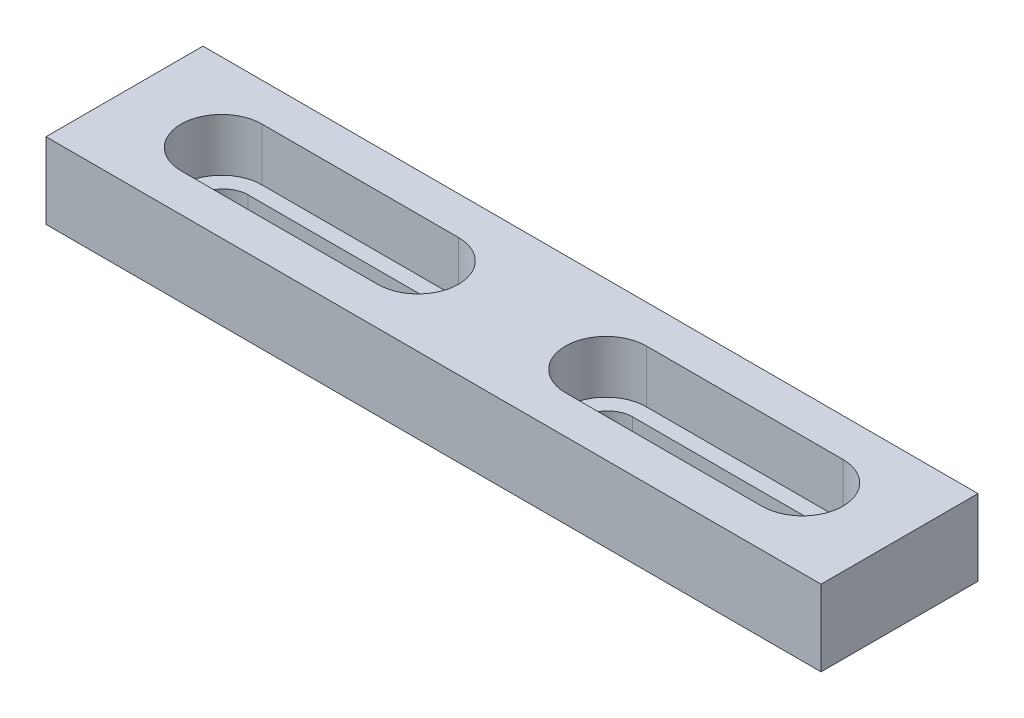
from build123d import *

# Parameters (mm, degrees)
SKETCH_2_W          = 100
SKETCH_2_H          = 20.25
EXTRUDE_2_DEPTH     = 9.8
CUT_EXTRUDE_4_DEPTH = 9.8
EXTRUDE_3_DEPTH     = 3


with BuildPart() as part:
    # 草图2 → 凸台-拉伸2 (new body)
    with BuildSketch(Plane(origin=(0, 0, 0), x_dir=(1, 0, 0), z_dir=(0, 1, 0))):
        Rectangle(SKETCH_2_W, SKETCH_2_H)
    extrude(amount=EXTRUDE_2_DEPTH)

    # 草图6 → 切除-拉伸4 (cut)
    with BuildSketch(Plane(origin=(0, 0, 0), x_dir=(1, 0, 0), z_dir=(0, 1, 0))):
        with BuildLine():
            Line((-37.475, 5.225), (-12.125, 5.225))
            ThreePointArc((-12.125, 5.225), (-6.9, 0), (-12.125, -5.225))
            Line((-12.125, -5.225), (-37.475, -5.225))
            ThreePointArc((-37.475, -5.225), (-42.7, 0), (-37.475, 5.225))
        make_face()
        with BuildLine():
            Line((37.475, -5.225), (12.125, -5.225))
            ThreePointArc((12.125, -5.225), (6.9, 0), (12.125, 5.225))
            Line((12.125, 5.225), (37.475, 5.225))
            ThreePointArc((37.475, 5.225), (42.7, 0), (37.475, -5.225))
        make_face()
    extrude(amount=CUT_EXTRUDE_4_DEPTH, mode=Mode.SUBTRACT)

    # 草图8 → 凸台-拉伸3 (add)
    with BuildSketch(Plane.XZ):
        with BuildLine():
            Line((-37.475, 5.225), (-12.125, 5.225))
            ThreePointArc((-12.125, 5.225), (-6.9, 0), (-12.125, -5.225))
            Line((-12.125, -5.225), (-37.475, -5.225))
            ThreePointArc((-37.475, -5.225), (-42.7, 0), (-37.475, 5.225))
        make_face()
        with BuildLine():
            Line((-37.25, 3.215), (-12.35, 3.215))
            ThreePointArc((-12.35, 3.215), (-9.135, 0), (-12.35, -3.215))
            Line((-12.35, -3.215), (-37.25, -3.215))
            ThreePointArc((-37.25, -3.215), (-40.465, 0), (-37.25, 3.215))
        make_face(mode=Mode.SUBTRACT)
        with BuildLine():
            Line((37.475, 5.225), (12.125, 5.225))
            ThreePointArc((12.125, 5.225), (6.9, 0), (12.125, -5.225))
            Line((12.125, -5.225), (37.475, -5.225))
            ThreePointArc((37.475, -5.225), (42.7, 0), (37.475, 5.225))
        make_face()
        with BuildLine():
            Line((37.25, -3.215), (12.35, -3.215))
            ThreePointArc((12.35, -3.215), (9.135, 0), (12.35, 3.215))
            Line((12.35, 3.215), (37.25, 3.215))
            ThreePointArc((37.25, 3.215), (40.465, 0), (37.25, -3.215))
        make_face(mode=Mode.SUBTRACT)
    extrude(amount=-EXTRUDE_3_DEPTH)


solid = part.part
